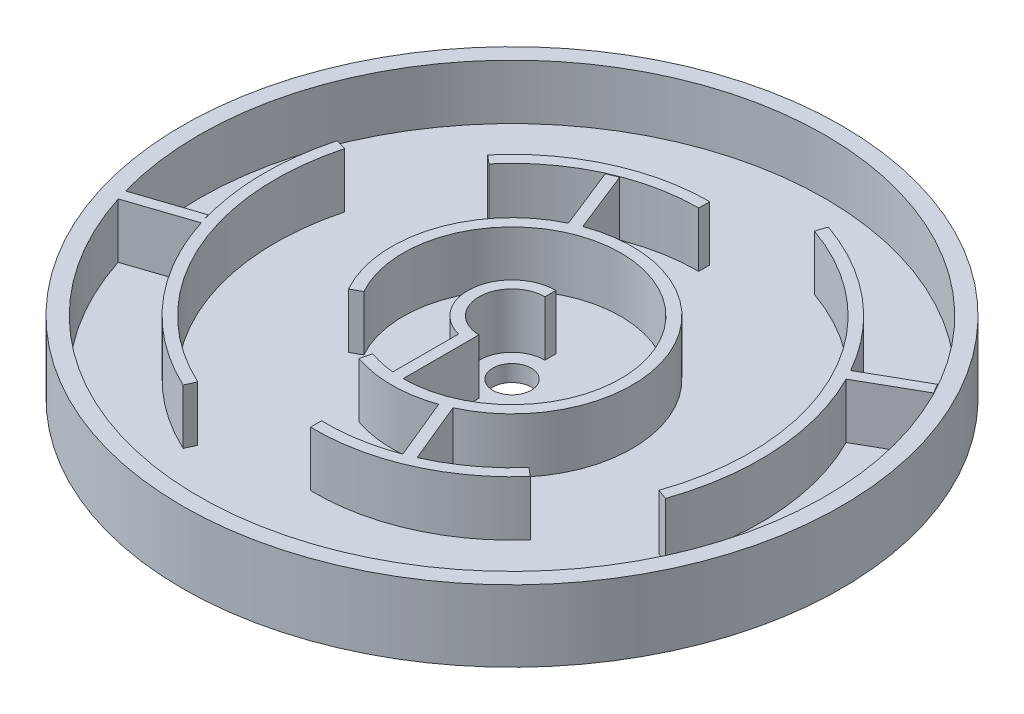
from build123d import *

# Parameters (mm, degrees)
SKETCH1_R            = 76.2
BOSS_EXTRUDE1_DEPTH  = 3.81
SKETCH2_R            = 76.2
SKETCH2_R_2          = 72.39
BOSS_EXTRUDE2_DEPTH  = 12.7
SKETCH3_R            = 4.445
CUT_EXTRUDE1_DEPTH   = 4.81
BOSS_EXTRUDE3_DEPTH  = 12.7
BOSS_EXTRUDE4_DEPTH  = 12.7
BOSS_EXTRUDE5_DEPTH  = 12.7
BOSS_EXTRUDE8_DEPTH  = 12.7
BOSS_EXTRUDE9_DEPTH  = 12.7
BOSS_EXTRUDE10_DEPTH = 12.7
BOSS_EXTRUDE11_DEPTH = 12.7
BOSS_EXTRUDE19_DEPTH = 12.7
BOSS_EXTRUDE20_DEPTH = 12.7
BOSS_EXTRUDE21_DEPTH = 12.7
BOSS_EXTRUDE22_DEPTH = 12.7


with BuildPart() as part:
    # Sketch1 → Boss-Extrude1 (new body)
    with BuildSketch(Plane(origin=(0, 0, 0), x_dir=(1, 0, 0), z_dir=(0, 1, 0))):
        Circle(SKETCH1_R)
    extrude(amount=BOSS_EXTRUDE1_DEPTH)

    # Sketch2 → Boss-Extrude2 (add)
    with BuildSketch(Plane(origin=(0, 3.81, 0), x_dir=(1, 0, 0), z_dir=(0, 1, 0))):
        Circle(SKETCH2_R)
        Circle(SKETCH2_R_2, mode=Mode.SUBTRACT)
    extrude(amount=BOSS_EXTRUDE2_DEPTH)

    # Sketch3 → Cut-Extrude1 (cut, through all)
    with BuildSketch(Plane(origin=(0, 3.81, 0), x_dir=(1, 0, 0), z_dir=(0, 1, 0))):
        Circle(SKETCH3_R)
    extrude(amount=-CUT_EXTRUDE1_DEPTH, mode=Mode.SUBTRACT)

    # Sketch4 → Boss-Extrude3 (add)
    with BuildSketch(Plane(origin=(0, 3.81, 0), x_dir=(1, 0, 0), z_dir=(0, 1, 0))):
        with BuildLine():
            Line((0, 7.62), (0, 10.16))
            ThreePointArc((0, 10.16), (-10.16, 0), (0, -10.16))
            Line((0, -10.16), (0, -7.62))
            ThreePointArc((0, -7.62), (-7.62, 0), (0, 7.62))
        make_face()
    extrude(amount=BOSS_EXTRUDE3_DEPTH)

    # Sketch5 → Boss-Extrude4 (add)
    with BuildSketch(Plane(origin=(0, 3.81, 0), x_dir=(1, 0, 0), z_dir=(0, 1, 0))):
        Polygon((0, -10.16), (0, -25.176651115), (-2.54, -25.176651115), (-2.520078124, -9.8425), align=None)
    extrude(amount=BOSS_EXTRUDE4_DEPTH)

    # Sketch6 → Boss-Extrude5 (add)
    with BuildSketch(Plane(origin=(0, 3.81, 0), x_dir=(1, 0, 0), z_dir=(0, 1, 0))):
        with BuildLine():
            Line((-21.983467268, -12.265166189), (-24.2679054, -13.539715513))
            ThreePointArc((-24.2679054, -13.539715513), (17.868925405, 21.282777862), (-9.135212339, -26.245057138))
            Line((-9.135212339, -26.245057138), (-8.472154438, -23.705057138))
            ThreePointArc((-8.472154438, -23.705057138), (16.266652993, 19.212057025), (-21.983467268, -12.265166189))
        make_face()
    extrude(amount=BOSS_EXTRUDE5_DEPTH)

    # Sketch7 → Boss-Extrude8 (add)
    with BuildSketch(Plane(origin=(0, 3.81, 0), x_dir=(1, 0, 0), z_dir=(0, 1, 0))):
        Polygon((9.247520886, -26.205695681), (15.12853456, -40.45434823), (17.476408475, -39.485282661), (11.601678734, -25.251854966), align=None)
    extrude(amount=BOSS_EXTRUDE8_DEPTH)

    # Sketch8 → Boss-Extrude9 (add)
    with BuildSketch(Plane(origin=(0, 3.81, 0), x_dir=(1, 0, 0), z_dir=(0, 1, 0))):
        with BuildLine():
            Line((-0.983739015, -43.049055689), (-0.983739015, -45.589055689))
            ThreePointArc((-0.983739015, -45.589055689), (18.37519714, -41.733462247), (34.290907527, -30.05766794))
            Line((34.290907527, -30.05766794), (32.345154642, -28.424987411))
            ThreePointArc((32.345154642, -28.424987411), (17.301746755, -39.431440468), (-0.983739015, -43.049055689))
        make_face()
    extrude(amount=BOSS_EXTRUDE9_DEPTH)

    # Sketch9 → Boss-Extrude10 (add)
    with BuildSketch(Plane(origin=(0, 3.81, 0), x_dir=(1, 0, 0), z_dir=(0, 1, 0))):
        Polygon((-9.684496714, 26.047373228), (-12.022324897, 25.054317646), (-17.646368783, 39.218629503), (-15.3085406, 40.211685084), align=None)
    extrude(amount=BOSS_EXTRUDE10_DEPTH)

    # Sketch10 → Boss-Extrude11 (add)
    with BuildSketch(Plane(origin=(0, 3.81, 0), x_dir=(1, 0, 0), z_dir=(0, 1, 0))):
        with BuildLine():
            Line((0, 43.18), (0, 45.72))
            ThreePointArc((0, 45.72), (-19.322106927, 41.436392023), (-35.023551939, 29.388249515))
            Line((-35.023551939, 29.388249515), (-33.077799054, 27.755568986))
            ThreePointArc((-33.077799054, 27.755568986), (-18.248656542, 39.134370244), (0, 43.18))
        make_face()
    extrude(amount=BOSS_EXTRUDE11_DEPTH)

    # Sketch15 → Boss-Extrude19 (add)
    with BuildSketch(Plane(origin=(0, 16.51, 0), x_dir=(1, 0, 0), z_dir=(0, 1, 0))):
        with BuildLine():
            Line((18.813236265, 54.331808343), (17.982135906, 51.931626642))
            ThreePointArc((17.982135906, 51.931626642), (49.436495597, 24.005915117), (51.931626642, -17.982135906))
            Line((51.931626642, -17.982135906), (54.331808343, -18.813236265))
            ThreePointArc((54.331808343, -18.813236265), (51.721357052, 25.115423174), (18.813236265, 54.331808343))
        make_face()
    extrude(amount=-BOSS_EXTRUDE19_DEPTH)

    # Sketch16 → Boss-Extrude20 (add)
    with BuildSketch(Plane(origin=(0, 3.81, 0), x_dir=(1, 0, 0), z_dir=(0, 1, 0))):
        Polygon((62.923710936, 35.479950277), (64.179700672, 33.272216194), (50.933296173, 25.736277775), (49.677306437, 27.944011858), align=None)
    extrude(amount=BOSS_EXTRUDE20_DEPTH)

    # Sketch17 → Boss-Extrude21 (add)
    with BuildSketch(Plane(origin=(0, 3.81, 0), x_dir=(1, 0, 0), z_dir=(0, 1, 0))):
        Polygon((-69.78543957, -19.725953422), (-68.982438616, -22.135681513), (-54.524070075, -17.317675793), (-55.327071028, -14.907947702), align=None)
    extrude(amount=BOSS_EXTRUDE21_DEPTH)

    # Sketch18 → Boss-Extrude22 (add)
    with BuildSketch(Plane(origin=(0, 3.81, 0), x_dir=(1, 0, 0), z_dir=(0, 1, 0))):
        with BuildLine():
            Line((-24.16501099, -51.873510961), (-23.092435835, -49.571081258))
            ThreePointArc((-23.092435835, -49.571081258), (-49.553841631, -23.129407029), (-52.827537989, 14.135201447))
            Line((-52.827537989, 14.135201447), (-55.281645892, 14.790149527))
            ThreePointArc((-55.281645892, 14.790149527), (-51.855122504, -24.204445165), (-24.16501099, -51.873510961))
        make_face()
    extrude(amount=BOSS_EXTRUDE22_DEPTH)


solid = part.part
